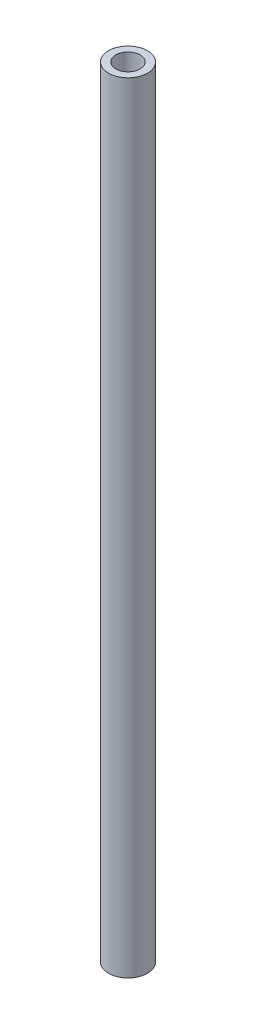
from build123d import *

# Parameters (mm, degrees)
SKETCH1_R           = 12.7
SKETCH1_R_2         = 7.9375
BOSS_EXTRUDE1_DEPTH = 508


with BuildPart() as part:
    # Sketch1 → Boss-Extrude1 (new body)
    with BuildSketch(Plane(origin=(0, 0, 0), x_dir=(1, 0, 0), z_dir=(0, 1, 0))):
        Circle(SKETCH1_R)
        Circle(SKETCH1_R_2, mode=Mode.SUBTRACT)
    extrude(amount=BOSS_EXTRUDE1_DEPTH)


solid = part.part
